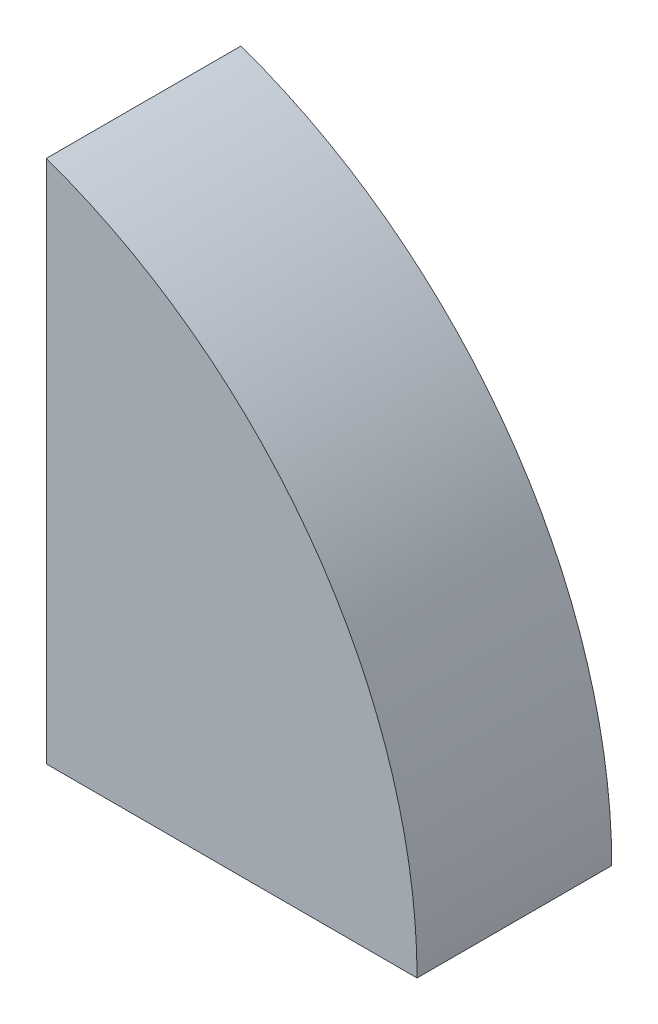
from build123d import *

# Parameters (mm, degrees)
BOSS_EXTRU_4_DEPTH = 70


with BuildPart() as part:
    # Esquisse2 → Boss.-Extru.4 (new body)
    with BuildSketch(Plane.XY):
        with BuildLine():
            Line((141.783657827, -169.122807018), (275.116991161, -169.122807018))
            ThreePointArc((275.116991161, -169.122807018), (238.416307346, -53.65275318), (141.783657827, 19.439001299))
            Line((141.783657827, 19.439001299), (141.783657827, -169.122807018))
        make_face()
    extrude(amount=BOSS_EXTRU_4_DEPTH)


solid = part.part
